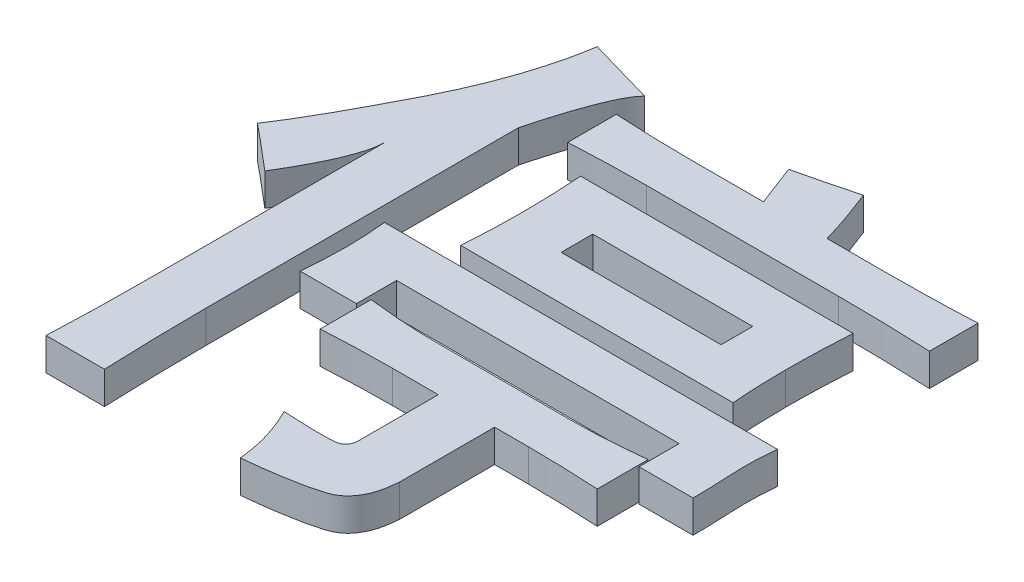
from build123d import *

# Parameters (mm, degrees)
SKETCH_1_W        = 9.88174139
SKETCH_1_H        = 1.95451592
EXTRUDE_1_DEPTH   = 2
EXTRUDE_1_2_DEPTH = 2
EXTRUDE_1_3_DEPTH = 2
EXTRUDE_1_4_DEPTH = 2
EXTRUDE_1_5_DEPTH = 2


with BuildPart() as part:
    # 草图1 → 凸台-拉伸1 (new body)
    with BuildSketch(Plane(origin=(0, 0, 0), x_dir=(1, 0, 0), z_dir=(0, 1, 0))):
        with BuildLine():
            add(Edge.make_bspline(
                [(30.752436647, 22.154645874), (30.73216565, 21.837622414), (30.690867567, 21.191750823), (30.650674713, 20.200398996), (30.624042271, 19.167568844), (30.619565925, 18.463954972), (30.617283951, 18.105263158)],
                knots=[0, 0, 0, 0, 0.940672631, 1.916431444, 2.937827954, 4, 4, 4, 4], degree=3))
            add(Edge.make_bspline(
                [(30.617283951, 18.105263158), (30.619485556, 17.788152365), (30.623721106, 17.178079977), (30.649991291, 16.301153107), (30.689389604, 15.496773518), (30.732035439, 14.986262208), (30.752436647, 14.742040286)],
                knots=[0, 0, 0, 0, 1.130183773, 2.174299741, 3.126608915, 4, 4, 4, 4], degree=3))
            Line((30.752436647, 14.742040286), (13.915529565, 14.742040286))
            add(Edge.make_bspline(
                [(13.915529565, 14.742040286), (13.956255794, 15.353468465), (14.036957897, 16.565059618), (14.046135918, 17.779294289), (14.050682261, 18.380766732)],
                knots=[0, 0, 0, 0, 1.009297861, 2, 2, 2, 2], degree=3))
            add(Edge.make_bspline(
                [(14.050682261, 18.380766732), (14.045600336, 18.989140946), (14.035082083, 20.248316282), (13.956265623, 21.505087377), (13.915529565, 22.154645874)],
                knots=[0, 0, 0, 0, 0.966305797, 2, 2, 2, 2], degree=3))
            Line((13.915529565, 22.154645874), (30.752436647, 22.154645874))
        make_face()
        with Locations((22.333983106, 18.44834308)):
            Rectangle(SKETCH_1_W, SKETCH_1_H, mode=Mode.SUBTRACT)
    extrude(amount=EXTRUDE_1_DEPTH)


with BuildPart() as body_2:
    # 草图1 → Extrude 1 2 (new body)
    with BuildSketch(Plane(origin=(0, 0, 0), x_dir=(1, 0, 0), z_dir=(0, 1, 0))):
        with BuildLine():
            add(Edge.make_bspline(
                [(11.607537362, 28.413255361), (11.521542323, 28.313099671), (11.327923123, 28.087597541), (11.076918098, 27.65935085), (10.811135115, 27.126477181), (10.546157248, 26.479367048), (10.265160581, 25.725940356), (9.980406671, 24.860307783), (9.691689727, 23.883248871), (9.502730954, 23.192907405), (9.403508772, 22.830409357)],
                knots=[0, 0, 0, 0, 0.523456493, 1.178570636, 1.963415983, 2.888813059, 3.953691545, 5.157215534, 6.507254928, 8, 8, 8, 8], degree=3))
            Line((9.403508772, 22.830409357), (9.403508772, 3.503573749))
            add(Edge.make_bspline(
                [(9.403508772, 3.503573749), (9.410266068, 2.429169112), (9.423674472, 0.297243697), (9.500535371, -1.833335456), (9.538661468, -2.890188434)],
                knots=[0, 0, 0, 0, 1.007919536, 2, 2, 2, 2], degree=3))
            Line((9.538661468, -2.890188434), (5.925925926, -2.890188434))
            add(Edge.make_bspline(
                [(5.925925926, -2.890188434), (5.966656183, -1.831622522), (6.046831028, 0.252095156), (6.056380469, 2.337326439), (6.061078622, 3.363222872)],
                knots=[0, 0, 0, 0, 1.016035831, 2, 2, 2, 2], degree=3))
            Line((6.061078622, 3.363222872), (6.061078622, 17.907732294))
            add(Edge.make_bspline(
                [(6.061078622, 17.907732294), (6.054446784, 17.760031814), (6.040198533, 17.442702988), (5.932875038, 16.939003937), (5.756161218, 16.378771824), (5.522148965, 15.752337902), (5.212198692, 15.066272423), (4.830354437, 14.321780096), (4.388784833, 13.511648511), (4.056802228, 12.961247126), (3.883040936, 12.673164392)],
                knots=[0, 0, 0, 0, 0.619094777, 1.330101432, 2.150575959, 3.081708728, 4.132179584, 5.305151966, 6.589503572, 8, 8, 8, 8], degree=3))
            add(Edge.make_bspline(
                [(3.883040936, 12.673164392), (3.61276359, 12.901918393), (3.098459777, 13.337208501), (2.36679578, 13.955572674), (1.712075511, 14.503845986), (1.296514497, 14.839602725), (1.102014295, 14.996751137)],
                knots=[0, 0, 0, 0, 1.172450442, 2.231025808, 3.172044959, 4, 4, 4, 4], degree=3))
            add(Edge.make_bspline(
                [(1.102014295, 14.996751137), (1.21531554, 15.16959098), (1.456199164, 15.537056383), (1.825244862, 16.131581324), (2.224973102, 16.80258347), (2.654969783, 17.549329432), (3.113766194, 18.371756588), (3.594890024, 19.274208026), (4.115048488, 20.247738691), (4.653465803, 21.281544176), (5.185718362, 22.344216921), (5.667164033, 23.417493406), (6.106904055, 24.47439099), (6.485086103, 25.523657296), (6.819621795, 26.556082101), (7.100785324, 27.577538036), (7.333166893, 28.586526237), (7.445412966, 29.259915409), (7.500974659, 29.593242365)],
                knots=[0, 0, 0, 0, 0.618227761, 1.314380472, 2.093112693, 2.954648851, 3.892101542, 4.910205721, 6.013985109, 7.194057854, 8.397175083, 9.5687473, 10.712315215, 11.82078272, 12.904330774, 13.958148685, 14.989285673, 16, 16, 16, 16], degree=3))
            Line((7.500974659, 29.593242365), (11.607537362, 28.413255361))
        make_face()
    extrude(amount=EXTRUDE_1_2_DEPTH)


with BuildPart() as body_3:
    # 草图1 → Extrude 1 3 (new body)
    with BuildSketch(Plane(origin=(0, 0, 0), x_dir=(1, 0, 0), z_dir=(0, 1, 0))):
        with BuildLine():
            add(Edge.make_bspline(
                [(26.645873944, 8.795321637), (26.978614485, 8.798309179), (27.675657914, 8.804567647), (28.762524405, 8.859765502), (29.937366391, 8.949624727), (30.74738061, 9.029381121), (31.168291098, 9.070825211)],
                knots=[0, 0, 0, 0, 0.880852809, 1.845259559, 2.88032478, 4, 4, 4, 4], degree=3))
            Line((31.168291098, 9.070825211), (31.168291098, 5.925925926))
            add(Edge.make_bspline(
                [(31.168291098, 5.925925926), (30.75244187, 5.944949905), (29.955478765, 5.981408813), (28.808724937, 6.034436913), (27.761793894, 6.051230537), (27.096381762, 6.057912077), (26.781026641, 6.061078622)],
                knots=[0, 0, 0, 0, 1.137978811, 2.180903712, 3.137885676, 4, 4, 4, 4], degree=3))
            Line((26.781026641, 6.061078622), (24.691358025, 6.061078622))
            Line((24.691358025, 6.061078622), (24.691358025, 0.192332684))
            add(Edge.make_bspline(
                [(24.691358025, 0.192332684), (24.674052596, 0.003016451), (24.64096282, -0.358975849), (24.538743939, -0.870597487), (24.390274776, -1.323140375), (24.190406787, -1.713181835), (23.94974424, -2.047884975), (23.660371455, -2.323801853), (23.320936211, -2.53361144), (22.938429345, -2.683331465), (22.515645079, -2.788633753), (22.060190664, -2.908217023), (21.561251132, -3.007774873), (21.022666365, -3.108627995), (20.445059899, -3.199186238), (19.827073029, -3.291045153), (19.169291141, -3.364535049), (18.716908791, -3.415195081), (18.484730344, -3.441195582)],
                knots=[0, 0, 0, 0, 1.123072812, 2.147431872, 3.076932964, 3.928891422, 4.727797385, 5.502981353, 6.275929502, 7.070886977, 7.920626468, 8.84961962, 9.853917622, 10.926593922, 12.088365901, 13.309345055, 14.619061764, 16, 16, 16, 16], degree=3))
            add(Edge.make_bspline(
                [(18.484730344, -3.441195582), (18.447772235, -3.126496661), (18.372547469, -2.485956507), (18.137072938, -1.52866004), (17.805162276, -0.559932353), (17.508484903, 0.068434331), (17.356725146, 0.389863548)],
                knots=[0, 0, 0, 0, 0.945914169, 1.925319627, 2.938736085, 4, 4, 4, 4], degree=3))
            add(Edge.make_bspline(
                [(17.356725146, 0.389863548), (17.56808733, 0.378740031), (17.968188494, 0.357683607), (18.536682733, 0.338887253), (19.039092032, 0.320682177), (19.477565779, 0.316592012), (19.851893774, 0.316400558), (20.162126425, 0.319430227), (20.409065349, 0.333019925), (20.642304845, 0.364960025), (20.877324162, 0.428743953), (21.078569545, 0.611421917), (21.200524927, 0.864153535), (21.209114633, 1.055418828), (21.213775179, 1.159194282)],
                knots=[0, 0, 0, 0, 1.74879159, 3.310400848, 4.699819061, 5.902536763, 6.933364607, 7.792507111, 8.466778008, 8.972962285, 9.742628753, 10.432229362, 11.149369409, 12, 12, 12, 12], degree=3))
            Line((21.213775179, 1.159194282), (21.213775179, 6.061078622))
            Line((21.213775179, 6.061078622), (18.380766732, 6.061078622))
            add(Edge.make_bspline(
                [(18.380766732, 6.061078622), (18.037688866, 6.05796704), (17.339354629, 6.051633422), (16.273333377, 6.035251169), (15.173295608, 5.983312344), (14.428397417, 5.945234195), (14.050682261, 5.925925926)],
                knots=[0, 0, 0, 0, 0.950238572, 1.934208509, 2.952500133, 4, 4, 4, 4], degree=3))
            Line((14.050682261, 5.925925926), (14.050682261, 9.070825211))
            add(Edge.make_bspline(
                [(14.050682261, 9.070825211), (14.435157731, 9.029005521), (15.194593814, 8.946401079), (16.324656519, 8.858001123), (17.428951949, 8.803670785), (18.157185557, 8.798077122), (18.515919428, 8.795321637)],
                knots=[0, 0, 0, 0, 1.036747421, 2.047837798, 3.038348828, 4, 4, 4, 4], degree=3))
            Line((18.515919428, 8.795321637), (26.645873944, 8.795321637))
        make_face()
    extrude(amount=EXTRUDE_1_3_DEPTH)


with BuildPart() as body_4:
    # 草图1 → Extrude 1 4 (new body)
    with BuildSketch(Plane(origin=(0, 0, 0), x_dir=(1, 0, 0), z_dir=(0, 1, 0))):
        with BuildLine():
            add(Edge.make_bspline(
                [(34.60948668, 13.614035088), (34.569631585, 13.143050758), (34.492198913, 12.227996483), (34.522408867, 10.887416718), (34.598335958, 9.624329928), (34.605839606, 8.804115246), (34.60948668, 8.40545809)],
                knots=[0, 0, 0, 0, 1.087231053, 2.112332324, 3.082517973, 4, 4, 4, 4], degree=3))
            Line((34.60948668, 8.40545809), (31.272254711, 8.40545809))
            Line((31.272254711, 8.40545809), (31.272254711, 10.884990253))
            Line((31.272254711, 10.884990253), (13.811565952, 10.884990253))
            Line((13.811565952, 10.884990253), (13.811565952, 8.40545809))
            Line((13.811565952, 8.40545809), (10.333983106, 8.40545809))
            add(Edge.make_bspline(
                [(10.333983106, 8.40545809), (10.352948484, 8.663630337), (10.389088662, 9.155600013), (10.442196382, 9.858561772), (10.459194504, 10.491588156), (10.465959712, 10.890189788), (10.469135802, 11.077322937)],
                knots=[0, 0, 0, 0, 1.160906096, 2.212207559, 3.160677723, 4, 4, 4, 4], degree=3))
            add(Edge.make_bspline(
                [(10.469135802, 11.077322937), (10.464130171, 11.488262006), (10.453808118, 12.335654606), (10.374718556, 13.179439647), (10.333983106, 13.614035088)],
                knots=[0, 0, 0, 0, 0.969890625, 2, 2, 2, 2], degree=3))
            Line((10.333983106, 13.614035088), (34.60948668, 13.614035088))
        make_face()
    extrude(amount=EXTRUDE_1_4_DEPTH)


with BuildPart() as body_5:
    # 草图1 → Extrude 1 5 (new body)
    with BuildSketch(Plane(origin=(0, 0, 0), x_dir=(1, 0, 0), z_dir=(0, 1, 0))):
        with BuildLine():
            add(Edge.make_bspline(
                [(23.67251462, 29.868745939), (23.789853619, 29.569461312), (24.020237528, 28.981844556), (24.338018683, 28.10910085), (24.619394923, 27.261054219), (24.786282718, 26.701742091), (24.868096166, 26.427550357)],
                knots=[0, 0, 0, 0, 1.058463999, 2.078192886, 3.057871984, 4, 4, 4, 4], degree=3))
            Line((24.868096166, 26.427550357), (28.298895387, 26.427550357))
            add(Edge.make_bspline(
                [(28.298895387, 26.427550357), (28.820458839, 26.429792654), (29.83592653, 26.434158334), (31.31749475, 26.460826088), (32.716002289, 26.500404282), (33.620149275, 26.542361974), (34.058479532, 26.562703054)],
                knots=[0, 0, 0, 0, 1.086266147, 2.114926136, 3.086116612, 4, 4, 4, 4], degree=3))
            Line((34.058479532, 26.562703054), (34.058479532, 23.558154646))
            add(Edge.make_bspline(
                [(34.058479532, 23.558154646), (33.100423962, 23.598872398), (31.181419953, 23.68043085), (29.260702059, 23.689010867), (28.298895387, 23.693307342)],
                knots=[0, 0, 0, 0, 0.998492516, 2, 2, 2, 2], degree=3))
            Line((28.298895387, 23.693307342), (16.452241715, 23.693307342))
            add(Edge.make_bspline(
                [(16.452241715, 23.693307342), (16.081439809, 23.690195502), (15.324196243, 23.68384057), (14.162914113, 23.667310478), (12.953704588, 23.615223235), (12.130805389, 23.577418083), (11.711500975, 23.558154646)],
                knots=[0, 0, 0, 0, 0.938155192, 1.915880067, 2.938046497, 4, 4, 4, 4], degree=3))
            Line((11.711500975, 23.558154646), (11.711500975, 26.562703054))
            add(Edge.make_bspline(
                [(11.711500975, 26.562703054), (12.506675075, 26.524589671), (14.086050958, 26.448888818), (15.667172945, 26.434630158), (16.452241715, 26.427550357)],
                knots=[0, 0, 0, 0, 1.006947249, 2, 2, 2, 2], degree=3))
            Line((16.452241715, 26.427550357), (20.938271605, 26.427550357))
            add(Edge.make_bspline(
                [(20.938271605, 26.427550357), (20.869047408, 26.611251641), (20.724019476, 26.996114424), (20.494855563, 27.598933852), (20.246521426, 28.255028931), (20.068925554, 28.708005059), (19.976608187, 28.943469786)],
                knots=[0, 0, 0, 0, 0.874609537, 1.832347895, 2.873217421, 4, 4, 4, 4], degree=3))
            add(Edge.make_bspline(
                [(19.976608187, 28.943469786), (20.254044541, 29.006736773), (20.82895339, 29.137839819), (21.72067613, 29.359043494), (22.675782468, 29.602044012), (23.333088149, 29.777923451), (23.67251462, 29.868745939)],
                knots=[0, 0, 0, 0, 0.896174117, 1.857068916, 2.893410544, 4, 4, 4, 4], degree=3))
        make_face()
    extrude(amount=EXTRUDE_1_5_DEPTH)


solid = Compound([part.part, body_2.part, body_3.part, body_4.part, body_5.part])
